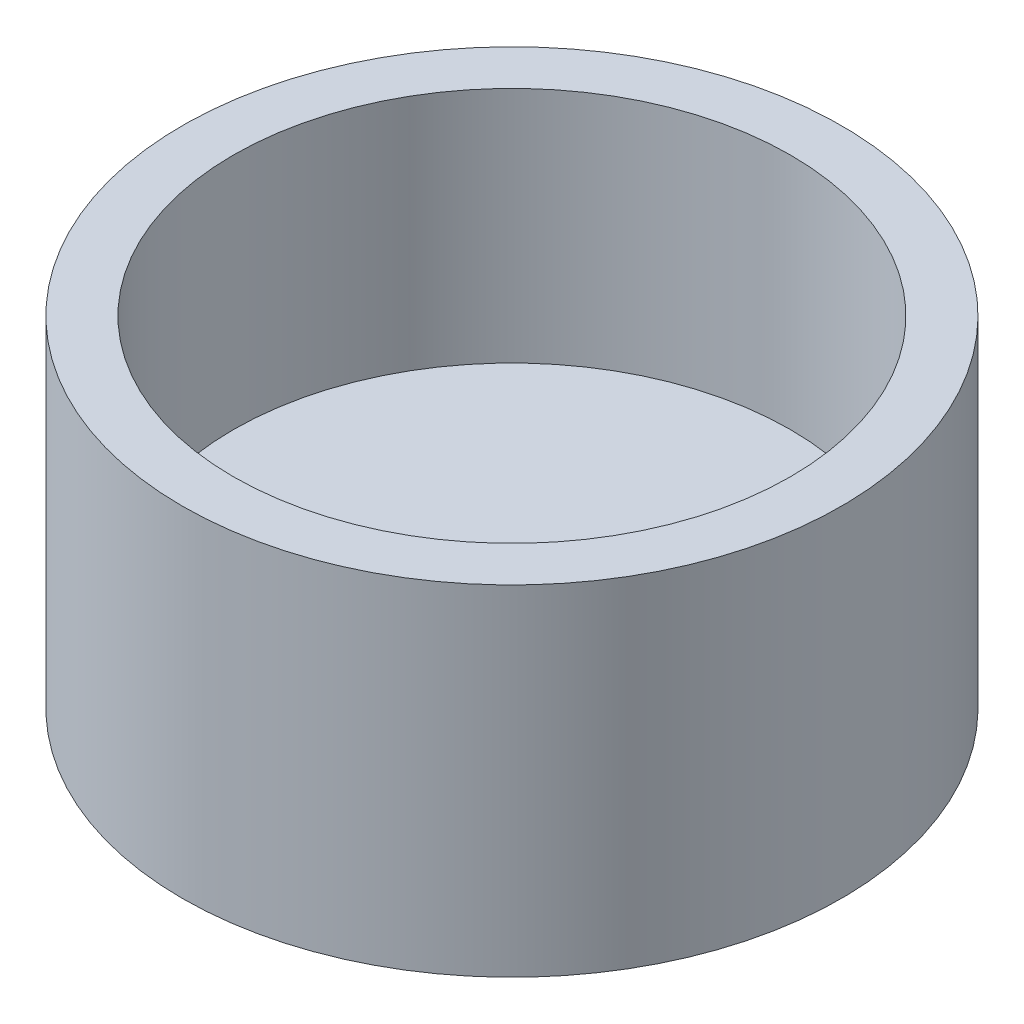
from build123d import *

# Parameters (mm, degrees)
SKETCH1_R                = 4.85
BOSS_EXTRUDE1_DEPTH      = 4
BOSS_EXTRUDE1_DEPTH_BACK = 1
SKETCH2_R                = 4.1
CUT_EXTRUDE1_DEPTH       = 3.5


with BuildPart() as part:
    # Sketch1 → Boss-Extrude1 (new body, two sides)
    with BuildSketch(Plane(origin=(0, 0, 0), x_dir=(1, 0, 0), z_dir=(0, 1, 0))) as boss_extrude1_sk:
        Circle(SKETCH1_R)
    extrude(amount=BOSS_EXTRUDE1_DEPTH)
    extrude(boss_extrude1_sk.sketch, amount=-BOSS_EXTRUDE1_DEPTH_BACK)

    # Sketch2 → Cut-Extrude1 (cut)
    with BuildSketch(Plane(origin=(0, 4, 0), x_dir=(1, 0, 0), z_dir=(0, 1, 0))):
        Circle(SKETCH2_R)
    extrude(amount=-CUT_EXTRUDE1_DEPTH, mode=Mode.SUBTRACT)


solid = part.part
